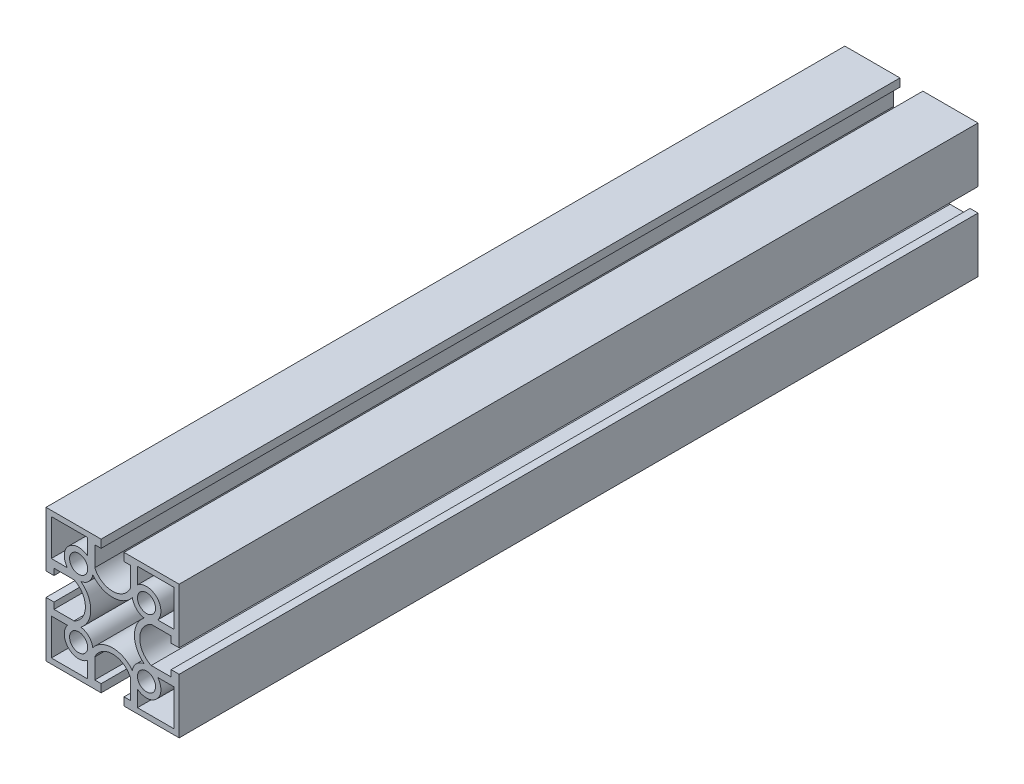
from build123d import *

# Parameters (mm, degrees)
SKETCH_1_R         = 3.4
EXTRUDE_1267_DEPTH = 150


with BuildPart() as part:
    # 草圖1 → Extrude 1267 (new body, symmetric)
    with BuildSketch(Plane.XY):
        with BuildLine():
            Line((4.3, 25), (25, 25))
            Line((25, 25), (25, 4.3))
            Line((25, 4.3), (22, 4.3))
            Line((22, 4.3), (22, 6.687301399))
            Line((22, 6.687301399), (14.5, 6.687301399))
            ThreePointArc((14.5, 6.687301399), (10.2, 0), (14.5, -6.687301399))
            Line((14.5, -6.687301399), (22, -6.687301399))
            Line((22, -6.687301399), (22, -4.3))
            Line((22, -4.3), (25, -4.3))
            Line((25, -4.3), (25, -25))
            Line((25, -25), (4.3, -25))
            Line((4.3, -25), (4.3, -22))
            Line((4.3, -22), (6.687301399, -22))
            Line((6.687301399, -22), (6.687301399, -14.5))
            ThreePointArc((6.687301399, -14.5), (0, -10.2), (-6.687301399, -14.5))
            Line((-6.687301399, -14.5), (-6.687301399, -22))
            Line((-6.687301399, -22), (-4.3, -22))
            Line((-4.3, -22), (-4.3, -25))
            Line((-4.3, -25), (-25, -25))
            Line((-25, -25), (-25, -4.3))
            Line((-25, -4.3), (-22, -4.3))
            Line((-22, -4.3), (-22, -6.687301399))
            Line((-22, -6.687301399), (-14.5, -6.687301399))
            ThreePointArc((-14.5, -6.687301399), (-10.2, 0), (-14.5, 6.687301399))
            Line((-14.5, 6.687301399), (-22, 6.687301399))
            Line((-22, 6.687301399), (-22, 4.3))
            Line((-22, 4.3), (-25, 4.3))
            Line((-25, 4.3), (-25, 25))
            Line((-25, 25), (-4.3, 25))
            Line((-4.3, 25), (-4.3, 22))
            Line((-4.3, 22), (-6.687301399, 22))
            Line((-6.687301399, 22), (-6.687301399, 14.5))
            ThreePointArc((-6.687301399, 14.5), (0, 10.2), (6.687301399, 14.5))
            Line((6.687301399, 14.5), (6.687301399, 22))
            Line((6.687301399, 22), (4.3, 22))
            Line((4.3, 22), (4.3, 25))
        make_face()
        with Locations((12.75, 12.75)):
            Circle(SKETCH_1_R, mode=Mode.SUBTRACT)
        with Locations((12.75, -12.75)):
            Circle(SKETCH_1_R, mode=Mode.SUBTRACT)
        with Locations((-12.75, -12.75)):
            Circle(SKETCH_1_R, mode=Mode.SUBTRACT)
        with Locations((-12.75, 12.75)):
            Circle(SKETCH_1_R, mode=Mode.SUBTRACT)
        with BuildLine():
            Line((9.35, 23), (23, 23))
            Line((23, 23), (23, 9.35))
            Line((23, 9.35), (16.945235393, 9.35))
            ThreePointArc((16.945235393, 9.35), (16.568376618, 16.568376618), (9.35, 16.945235393))
            Line((9.35, 16.945235393), (9.35, 23))
        make_face(mode=Mode.SUBTRACT)
        with BuildLine():
            Line((9.35, -23), (9.35, -16.945235393))
            ThreePointArc((9.35, -16.945235393), (16.568376618, -16.568376618), (16.945235393, -9.35))
            Line((16.945235393, -9.35), (23, -9.35))
            Line((23, -9.35), (23, -23))
            Line((23, -23), (9.35, -23))
        make_face(mode=Mode.SUBTRACT)
        with BuildLine():
            Line((-9.35, -23), (-23, -23))
            Line((-23, -23), (-23, -9.35))
            Line((-23, -9.35), (-16.945235393, -9.35))
            ThreePointArc((-16.945235393, -9.35), (-16.568376618, -16.568376618), (-9.35, -16.945235393))
            Line((-9.35, -16.945235393), (-9.35, -23))
        make_face(mode=Mode.SUBTRACT)
        with BuildLine():
            Line((-9.35, 23), (-9.35, 16.945235393))
            ThreePointArc((-9.35, 16.945235393), (-16.568376618, 16.568376618), (-16.945235393, 9.35))
            Line((-16.945235393, 9.35), (-23, 9.35))
            Line((-23, 9.35), (-23, 23))
            Line((-23, 23), (-9.35, 23))
        make_face(mode=Mode.SUBTRACT)
        with BuildLine():
            ThreePointArc((11.864845961, 7.423040048), (8.2, 0), (11.864845961, -7.423040048))
            ThreePointArc((11.864845961, -7.423040048), (8.931623382, -8.931623382), (7.423040048, -11.864845961))
            ThreePointArc((7.423040048, -11.864845961), (0, -8.2), (-7.423040048, -11.864845961))
            ThreePointArc((-7.423040048, -11.864845961), (-8.931623382, -8.931623382), (-11.864845961, -7.423040048))
            ThreePointArc((-11.864845961, -7.423040048), (-8.2, 0), (-11.864845961, 7.423040048))
            ThreePointArc((-11.864845961, 7.423040048), (-8.931623382, 8.931623382), (-7.423040048, 11.864845961))
            ThreePointArc((-7.423040048, 11.864845961), (0, 8.2), (7.423040048, 11.864845961))
            ThreePointArc((7.423040048, 11.864845961), (8.931623382, 8.931623382), (11.864845961, 7.423040048))
        make_face(mode=Mode.SUBTRACT)
    extrude(amount=EXTRUDE_1267_DEPTH, both=True)


solid = part.part
